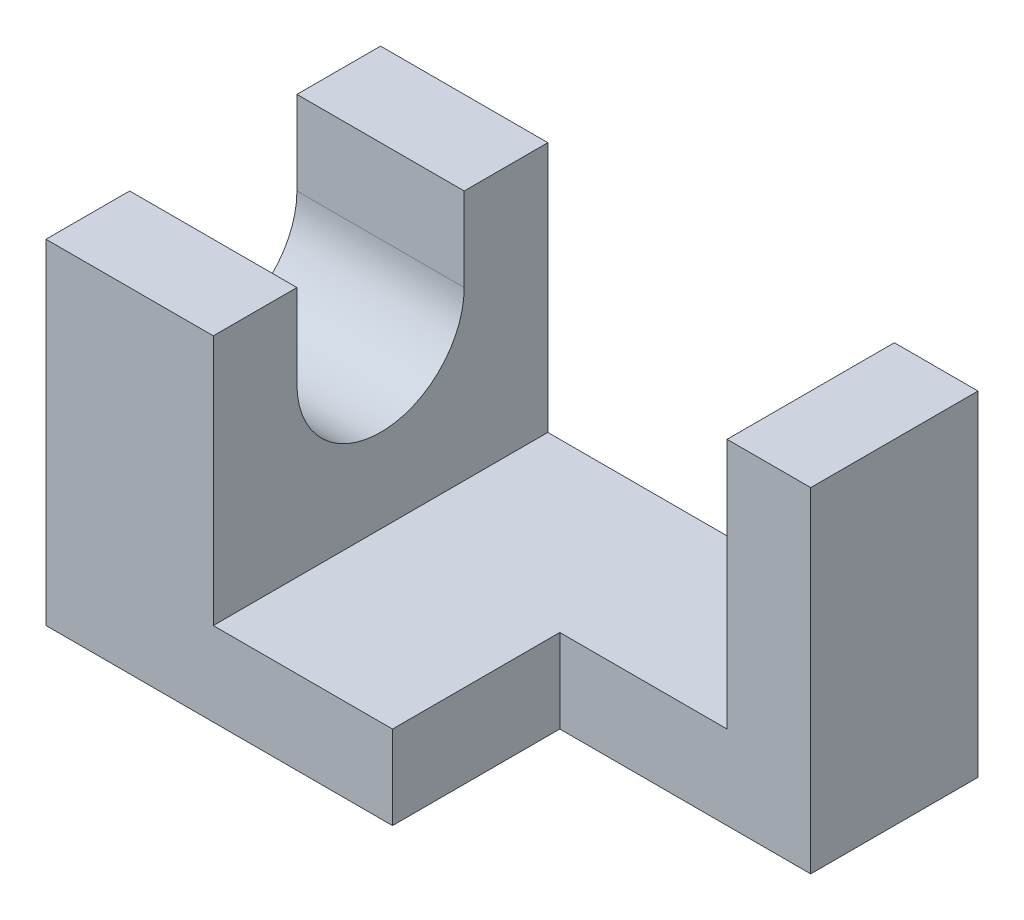
from build123d import *

# Parameters (mm, degrees)
EXTRUDE_1_DEPTH     = 14
SKETCH_2_W          = 21
SKETCH_2_H          = 14
CUT_EXTRUDE_1_DEPTH = 29
CUT_EXTRUDE_2_REACH = 52


with BuildPart() as part:
    # 스케치1 → 보스-돌출1 (new body, symmetric)
    with BuildSketch(Plane.XY):
        Polygon((0, 0), (0, 28), (14, 28), (14, 7), (43, 7), (43, 28), (50, 28), (50, 0), align=None)
    extrude(amount=EXTRUDE_1_DEPTH, both=True)

    # 스케치2 → 컷-돌출1 (cut, through all)
    with BuildSketch(Plane(origin=(0, 0, 0), x_dir=(1, 0, 0), z_dir=(0, 1, 0))):
        with Locations((39.5, -7)):
            Rectangle(SKETCH_2_W, SKETCH_2_H)
    extrude(amount=CUT_EXTRUDE_1_DEPTH, mode=Mode.SUBTRACT)

    # 스케치3 → 컷-돌출2 (cut, up to next)
    with BuildSketch(Plane(origin=(0, 0, 0), x_dir=(0, 0, -1), z_dir=(1, 0, 0)), mode=Mode.PRIVATE) as cut_extrude_2_sk1:
        with BuildLine():
            Line((-7, 21), (-7, 28))
            Line((-7, 28), (7, 28))
            Line((7, 28), (7, 21))
            ThreePointArc((7, 21), (0, 14), (-7, 21))
        make_face()
    cut_extrude_2_tool1 = extrude(cut_extrude_2_sk1.sketch, amount=CUT_EXTRUDE_2_REACH, mode=Mode.PRIVATE) & part.part
    add(cut_extrude_2_tool1.solids().sort_by_distance((0, 21.653449, 0))[0], mode=Mode.SUBTRACT)


solid = part.part
